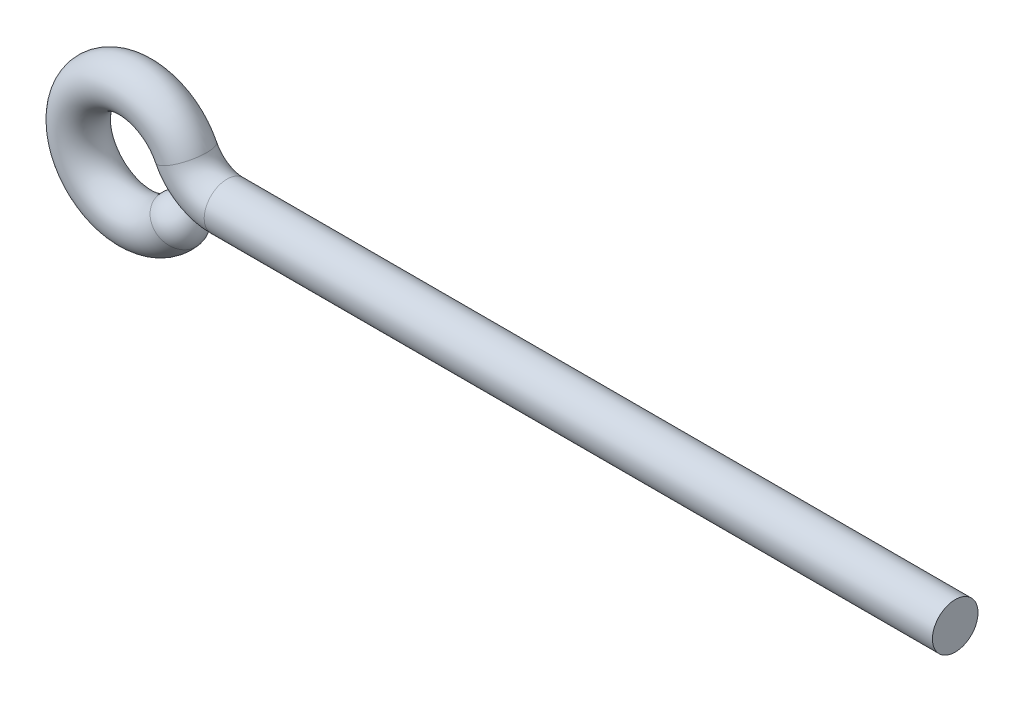
from build123d import *

# Parameters (mm, degrees)
SKETCH2_R           = 5
DOME3_FACE_RADIUS   = 5
DOME3_HEIGHT        = 5
SKETCH4_R           = 5
BOSS_EXTRUDE2_DEPTH = 150


with BuildPart() as part:
    # Sweep2: sweep along a path in Sketch1
    with BuildLine(Plane.XY) as sweep2_path:
        Line((0, 0), (-9.844355629, 0))
        ThreePointArc((-9.844355629, 0), (-15.114818396, 1.501634144), (-18.802419794, 5.555555556))
        ThreePointArc((-18.802419794, 5.555555556), (-42.411911207, 1.481371052), (-20.424444461, -8.034845121))
    # Sketch2 → Sweep2 (sweep)
    with BuildSketch(Plane(origin=(0, 0, 0), x_dir=(0, 0, -1), z_dir=(1, 0, 0))):
        Circle(SKETCH2_R)
    sweep(path=sweep2_path.line)

    # Dome3: a dome of height H over a round flat face of radius A is a cap of a sphere of radius (A * A + H * H) / (2 * H)
    dome3_r = (DOME3_FACE_RADIUS * DOME3_FACE_RADIUS + DOME3_HEIGHT * DOME3_HEIGHT) / (2 * DOME3_HEIGHT)
    dome3_base = Plane((-20.424444461, -8.034845121, 0), z_dir=(0.64278761, 0.766044443, 0))
    with Locations(dome3_base.offset(DOME3_HEIGHT - dome3_r)):
        dome3_ball = Sphere(dome3_r, mode=Mode.PRIVATE)
    add(split(dome3_ball, bisect_by=dome3_base, keep=Keep.TOP, mode=Mode.PRIVATE))

    # Sketch4 → Boss-Extrude2 (add)
    with BuildSketch(Plane(origin=(0, 0, 0), x_dir=(0, 0, -1), z_dir=(1, 0, 0))):
        Circle(SKETCH4_R)
    extrude(amount=BOSS_EXTRUDE2_DEPTH)


solid = part.part
